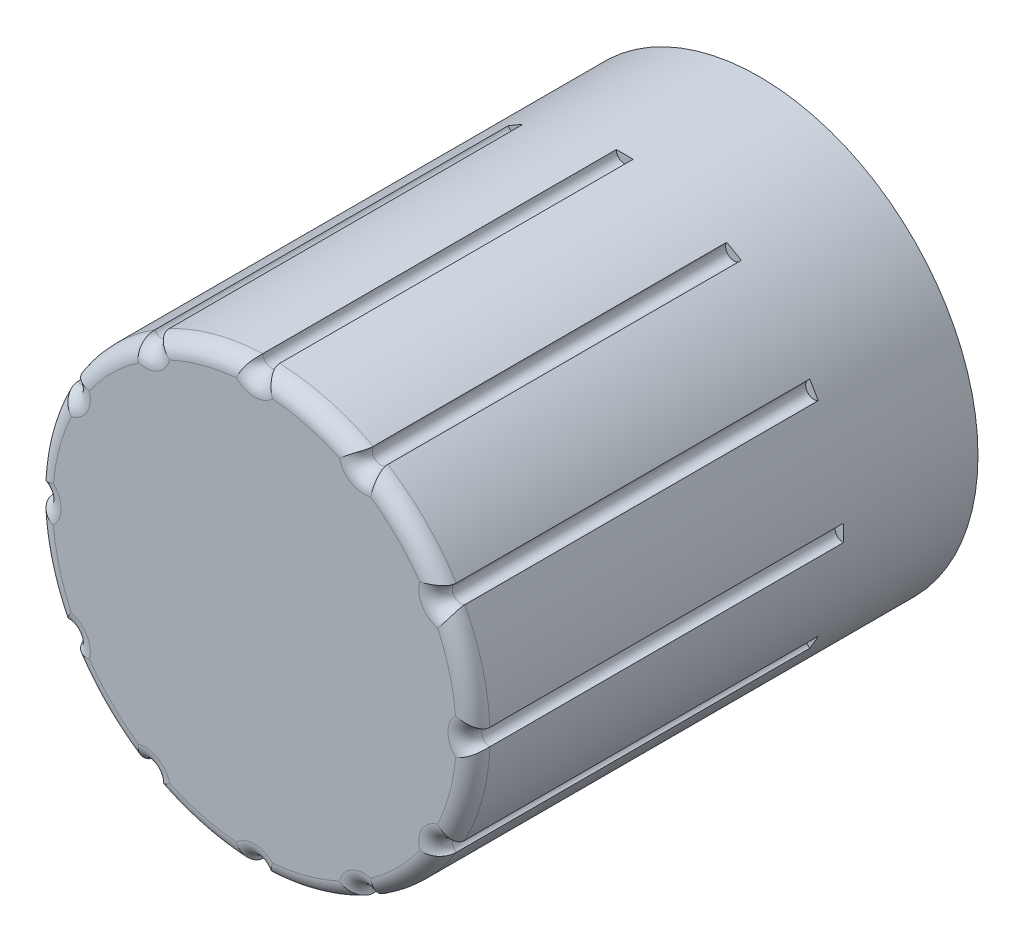
from build123d import *

# Parameters (mm, degrees)
SKIZZE1_R                       = 6.5
AUFSATZ_LINEAR_AUSTRAGEN1_DEPTH = 15
SCHNITT_LINEAR_AUSTRAGEN1_DEPTH = 10
SKIZZE3_R                       = 0.25
SCHNITT_LINEAR_AUSTRAGEN3_DEPTH = 11
VERRUNDUNG2_R                   = 0.5


with BuildPart() as part:
    # Skizze1 → Aufsatz-Linear austragen1 (new body)
    with BuildSketch(Plane.XY):
        Circle(SKIZZE1_R)
    extrude(amount=AUFSATZ_LINEAR_AUSTRAGEN1_DEPTH)

    # Skizze2 → Schnitt-Linear austragen1 (cut)
    with BuildSketch(Plane(origin=(0, 0, 0), x_dir=(-1, 0, 0), z_dir=(0, 0, -1))):
        with BuildLine():
            Line((-3.059411708, 1.7), (3.059411708, 1.7))
            ThreePointArc((3.059411708, 1.7), (0, -3.5), (-3.059411708, 1.7))
        make_face()
    extrude(amount=-SCHNITT_LINEAR_AUSTRAGEN1_DEPTH, mode=Mode.SUBTRACT)

    # Skizze3 → Schnitt-Linear austragen3 (cut)
    with BuildSketch(Plane.XY.offset(15)):
        with Locations((0, 6.5)):
            Circle(SKIZZE3_R)
        with Locations((3.25, 5.629165125)):
            Circle(SKIZZE3_R)
        with Locations((5.629165125, 3.25)):
            Circle(SKIZZE3_R)
        with Locations((6.5, 0)):
            Circle(SKIZZE3_R)
        with Locations((5.629165125, -3.25)):
            Circle(SKIZZE3_R)
        with Locations((3.25, -5.629165125)):
            Circle(SKIZZE3_R)
        with Locations((0, -6.5)):
            Circle(SKIZZE3_R)
        with Locations((-3.25, -5.629165125)):
            Circle(SKIZZE3_R)
        with Locations((-5.629165125, -3.25)):
            Circle(SKIZZE3_R)
        with Locations((-6.5, 0)):
            Circle(SKIZZE3_R)
        with Locations((-5.629165125, 3.25)):
            Circle(SKIZZE3_R)
        with Locations((-3.25, 5.629165125)):
            Circle(SKIZZE3_R)
    extrude(amount=-SCHNITT_LINEAR_AUSTRAGEN3_DEPTH, mode=Mode.SUBTRACT)

    # Verrundung2
    verrundung2_edges = [part.edges().sort_by_distance(p)[0] for p in [
        (4.596194078, 4.596194078, 15),
        (1.682323793, 6.278517871, 15),
        (-1.682323793, 6.278517871, 15),
        (-4.596194078, 4.596194078, 15),
        (-6.278517871, 1.682323793, 15),
        (-6.278517871, -1.682323793, 15),
        (-4.596194078, -4.596194078, 15),
        (-1.682323793, -6.278517871, 15),
        (1.682323793, -6.278517871, 15),
        (4.596194078, -4.596194078, 15),
        (6.278517871, -1.682323793, 15),
        (-5.412658774, -3.125, 15),
        (-3.125, -5.412658774, 15),
        (-6.25, 0, 15),
        (-5.412658774, 3.125, 15),
        (-3.125, 5.412658774, 15),
        (6.278517871, 1.682323793, 15),
        (0, 6.25, 15),
        (3.125, 5.412658774, 15),
        (5.412658774, 3.125, 15),
        (6.25, 0, 15),
        (5.412658774, -3.125, 15),
        (3.125, -5.412658774, 15),
        (0, -6.25, 15),
    ]]
    fillet(verrundung2_edges, radius=VERRUNDUNG2_R)


solid = part.part
